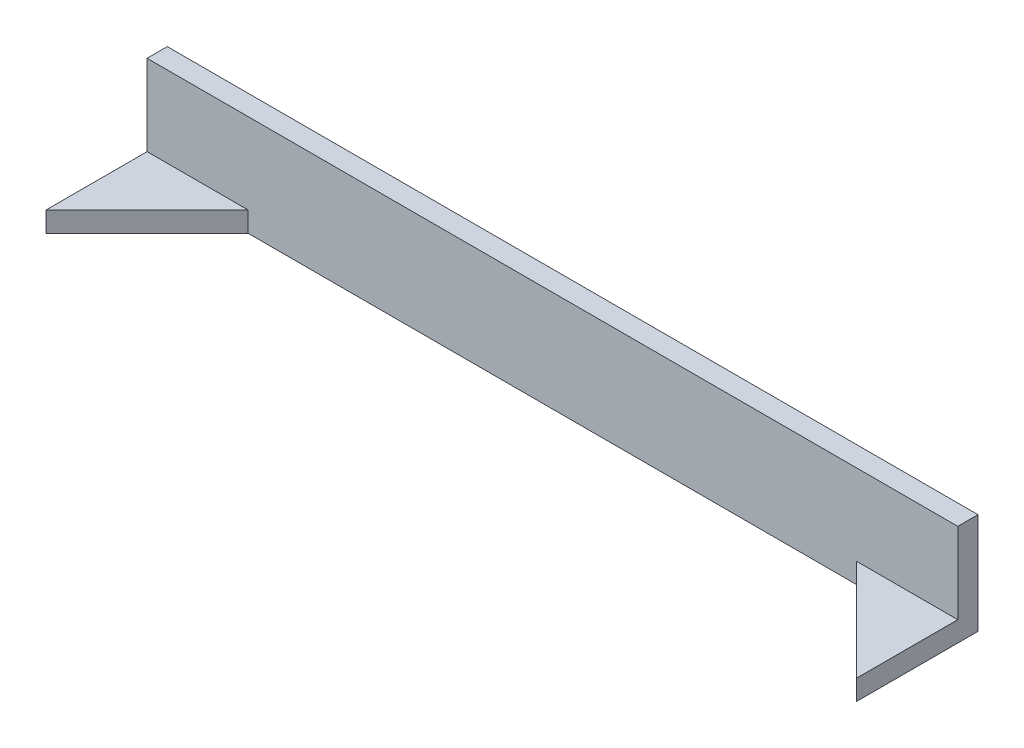
from build123d import *

# Parameters (mm, degrees)
SKETCH1_W           = 38
SKETCH1_H           = 190
BOSS_EXTRUDE1_DEPTH = 1524
SKETCH2_W           = 190
SKETCH2_H           = 38
BOSS_EXTRUDE2_DEPTH = 190
CUT_EXTRUDE1_DEPTH  = 190


with BuildPart() as part:
    # Sketch1 → Boss-Extrude1 (new body)
    with BuildSketch(Plane(origin=(0, 0, 0), x_dir=(0, 0, -1), z_dir=(1, 0, 0))):
        Rectangle(SKETCH1_W, SKETCH1_H)
    extrude(amount=BOSS_EXTRUDE1_DEPTH)

    # Sketch2 → Boss-Extrude2 (add)
    with BuildSketch(Plane.XY.offset(19)):
        with Locations((95, -76)):
            Rectangle(SKETCH2_W, SKETCH2_H)
        with Locations((1429, -76)):
            Rectangle(SKETCH2_W, SKETCH2_H)
    extrude(amount=BOSS_EXTRUDE2_DEPTH)

    # Sketch3 → Cut-Extrude1 (cut)
    with BuildSketch(Plane(origin=(0, -57, 0), x_dir=(1, 0, 0), z_dir=(0, 1, 0))):
        Polygon((190, -19), (0, -209), (190, -209), align=None)
        Polygon((1334, -19), (1524, -209), (1334, -209), align=None)
    extrude(amount=-CUT_EXTRUDE1_DEPTH, mode=Mode.SUBTRACT)


solid = part.part
